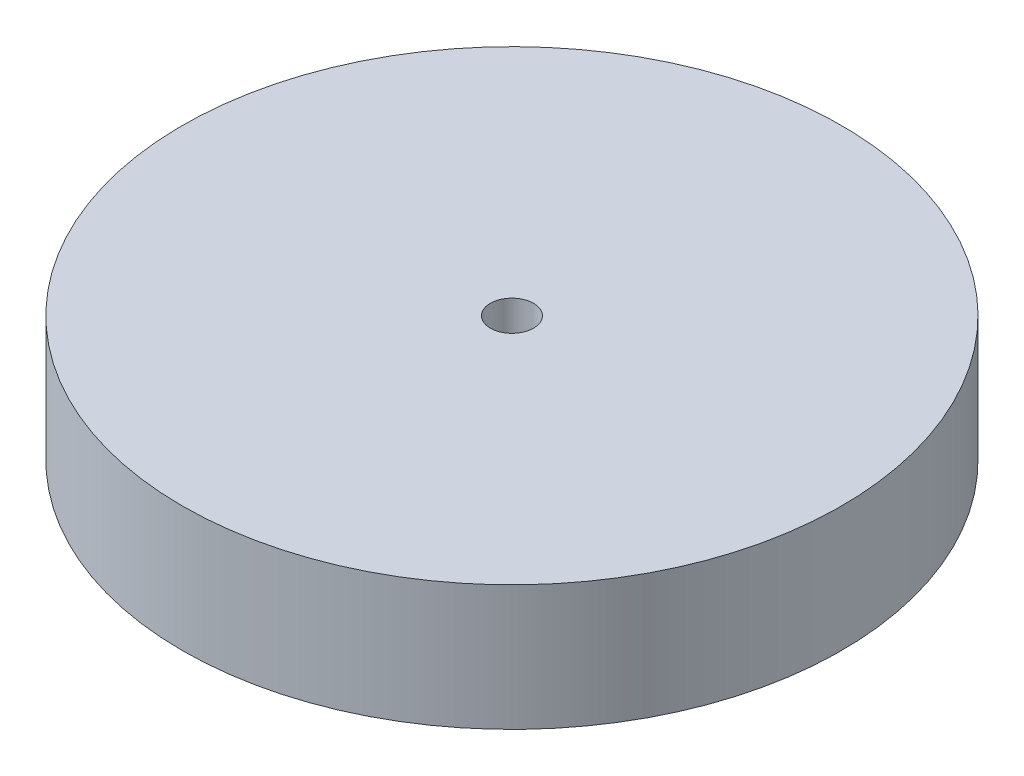
from build123d import *

# Parameters (mm, degrees)
SKETCH1_R           = 50
BOSS_EXTRUDE1_DEPTH = 19
SKETCH2_R           = 3.275
CUT_EXTRUDE2_DEPTH  = 20


with BuildPart() as part:
    # Sketch1 → Boss-Extrude1 (new body)
    with BuildSketch(Plane(origin=(0, 0, 0), x_dir=(1, 0, 0), z_dir=(0, 1, 0))):
        Circle(SKETCH1_R)
    extrude(amount=BOSS_EXTRUDE1_DEPTH)

    # Sketch2 → Cut-Extrude2 (cut, through all)
    with BuildSketch(Plane(origin=(0, 19, 0), x_dir=(1, 0, 0), z_dir=(0, 1, 0))):
        Circle(SKETCH2_R)
    extrude(amount=-CUT_EXTRUDE2_DEPTH, mode=Mode.SUBTRACT)


solid = part.part
